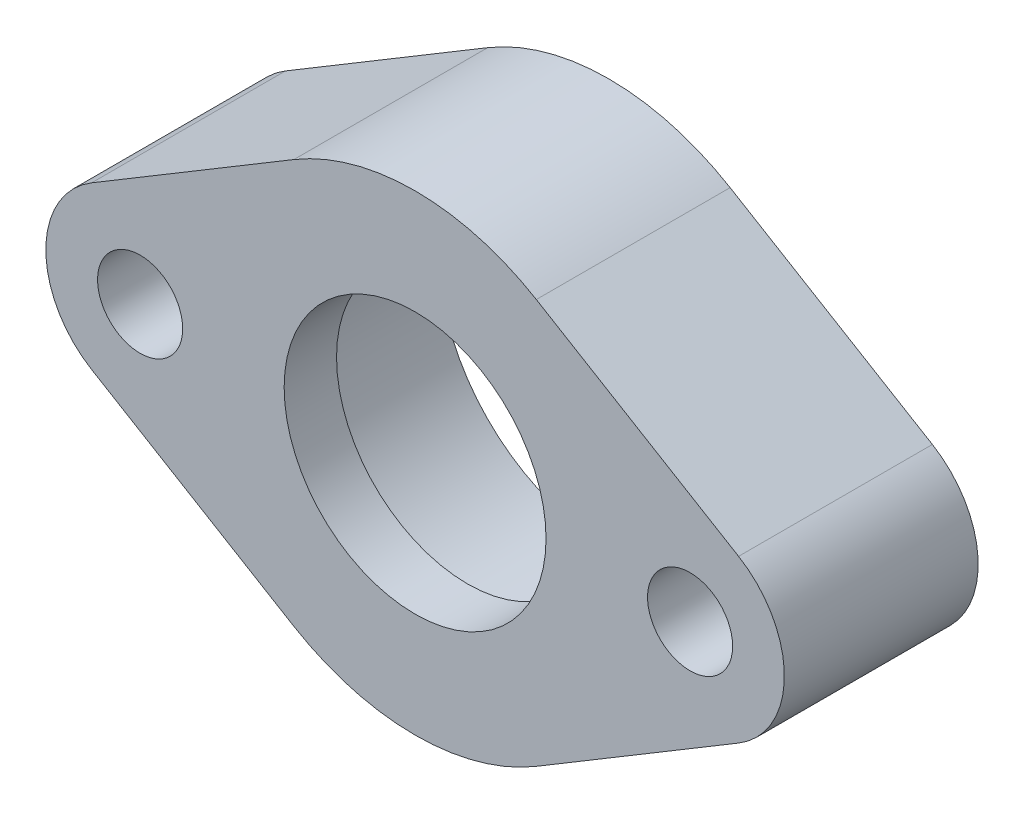
from build123d import *

# Parameters (mm, degrees)
SKETCH1_R          = 5.1562
EXTRUDE1_DEPTH     = 23.495
SKETCH6_R          = 20.64385
CUT_EXTRUDE1_DEPTH = 17.145
SKETCH7_R          = 15.875
CUT_EXTRUDE2_DEPTH = 7.35
FILLET1_R          = 0.127


with BuildPart() as part:
    # Sketch1 → Extrude1 (new body)
    with BuildSketch(Plane.XY):
        with BuildLine():
            Line((-39.215785714, 9.802584203), (-14.695714286, 24.506460508))
            ThreePointArc((-14.695714286, 24.506460508), (0, 28.575), (14.695714286, 24.506460508))
            Line((14.695714286, 24.506460508), (39.215785714, 9.802584203))
            ThreePointArc((39.215785714, 9.802584203), (44.7675, 0), (39.215785714, -9.802584203))
            Line((39.215785714, -9.802584203), (14.695714286, -24.506460508))
            ThreePointArc((14.695714286, -24.506460508), (0, -28.575), (-14.695714286, -24.506460508))
            Line((-14.695714286, -24.506460508), (-39.215785714, -9.802584203))
            ThreePointArc((-39.215785714, -9.802584203), (-44.7675, 0), (-39.215785714, 9.802584203))
        make_face()
        with Locations((-33.3375, 0)):
            Circle(SKETCH1_R, mode=Mode.SUBTRACT)
        with Locations((33.3375, 0)):
            Circle(SKETCH1_R, mode=Mode.SUBTRACT)
    extrude(amount=EXTRUDE1_DEPTH)

    # Sketch6 → Cut-Extrude1 (cut)
    with BuildSketch(Plane.XY):
        Circle(SKETCH6_R)
    extrude(amount=CUT_EXTRUDE1_DEPTH, mode=Mode.SUBTRACT)

    # Sketch7 → Cut-Extrude2 (cut, through all)
    with BuildSketch(Plane(origin=(0, 0, 17.145), x_dir=(-1, 0, 0), z_dir=(0, 0, -1))):
        Circle(SKETCH7_R)
    extrude(amount=-CUT_EXTRUDE2_DEPTH, mode=Mode.SUBTRACT)

    # Fillet1
    fillet1_edges = [part.edges().sort_by_distance(p)[0] for p in [
        (-20.64385, 0, 17.145),
    ]]
    fillet(fillet1_edges, radius=FILLET1_R)


solid = part.part
